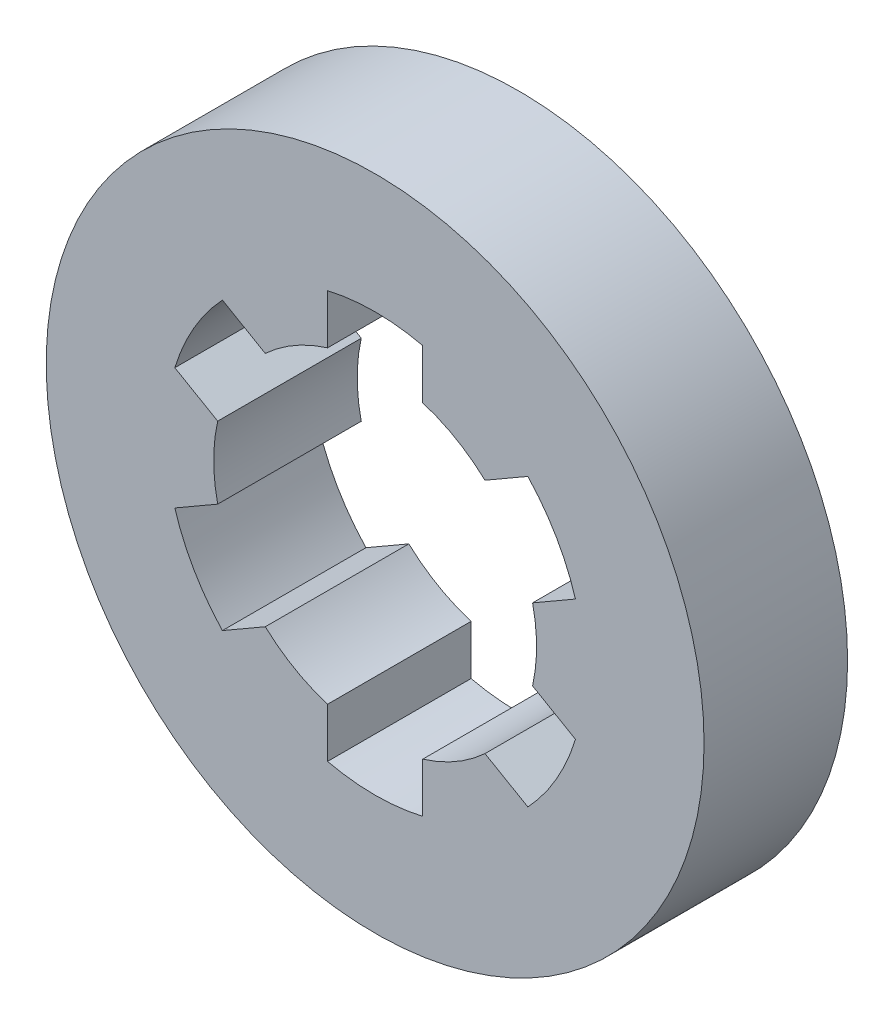
from build123d import *

# Parameters (mm, degrees)
SKETCH1_R           = 27.5
BOSS_EXTRUDE1_DEPTH = 12


with BuildPart() as part:
    # Sketch1 → Boss-Extrude1 (new body)
    with BuildSketch(Plane.XY):
        Circle(SKETCH1_R)
        with BuildLine():
            Line((-3.977272727, 12.900825619), (-3.977272727, 17.042045114))
            ThreePointArc((-3.977272727, 17.042045114), (0, 17.5), (3.977272727, 17.042045114))
            Line((3.977272727, 17.042045114), (3.977272727, 12.900825619))
            ThreePointArc((3.977272727, 12.900825619), (6.75, 11.691342951), (9.183806352, 9.894832029))
            Line((9.183806352, 9.894832029), (12.770207637, 11.965441776))
            ThreePointArc((12.770207637, 11.965441776), (15.155444566, 8.75), (16.747480364, 5.076603337))
            Line((16.747480364, 5.076603337), (13.16107908, 3.00599359))
            ThreePointArc((13.16107908, 3.00599359), (13.5, 0), (13.16107908, -3.00599359))
            Line((13.16107908, -3.00599359), (16.747480364, -5.076603337))
            ThreePointArc((16.747480364, -5.076603337), (15.155444566, -8.75), (12.770207637, -11.965441776))
            Line((12.770207637, -11.965441776), (9.183806352, -9.894832029))
            ThreePointArc((9.183806352, -9.894832029), (6.75, -11.691342951), (3.977272727, -12.900825619))
            Line((3.977272727, -12.900825619), (3.977272727, -17.042045114))
            ThreePointArc((3.977272727, -17.042045114), (0, -17.5), (-3.977272727, -17.042045114))
            Line((-3.977272727, -17.042045114), (-3.977272727, -12.900825619))
            ThreePointArc((-3.977272727, -12.900825619), (-6.75, -11.691342951), (-9.183806352, -9.894832029))
            Line((-9.183806352, -9.894832029), (-12.770207637, -11.965441776))
            ThreePointArc((-12.770207637, -11.965441776), (-15.155444566, -8.75), (-16.747480364, -5.076603337))
            Line((-16.747480364, -5.076603337), (-13.16107908, -3.00599359))
            ThreePointArc((-13.16107908, -3.00599359), (-13.5, 0), (-13.16107908, 3.00599359))
            Line((-13.16107908, 3.00599359), (-16.747480364, 5.076603337))
            ThreePointArc((-16.747480364, 5.076603337), (-15.155444566, 8.75), (-12.770207637, 11.965441776))
            Line((-12.770207637, 11.965441776), (-9.183806352, 9.894832029))
            ThreePointArc((-9.183806352, 9.894832029), (-6.75, 11.691342951), (-3.977272727, 12.900825619))
        make_face(mode=Mode.SUBTRACT)
    extrude(amount=BOSS_EXTRUDE1_DEPTH)


solid = part.part
